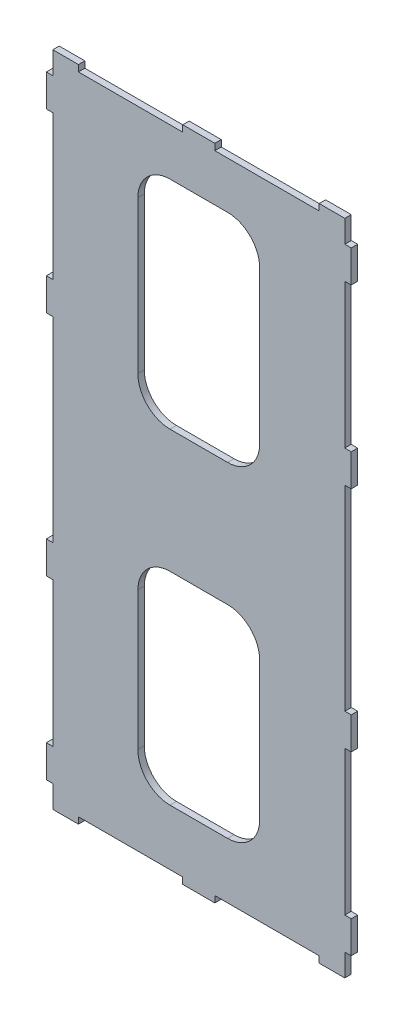
from build123d import *

# Parameters (mm, degrees)
BOSS_EXTRUDE2_DEPTH = 4


with BuildPart() as part:
    # Sketch1 → Boss-Extrude2 (new body)
    with BuildSketch(Plane.XY):
        Polygon((-75, -201), (-10, -201), (-10, -205), (10, -205), (10, -201), (75, -201), (75, -205), (91, -205), (91, -191), (95, -191), (95, -171), (91, -171), (91, -81), (95, -81), (95, -61), (91, -61), (91, 61), (95, 61), (95, 81), (91, 81), (91, 171), (95, 171), (95, 191), (91, 191), (91, 205), (75, 205), (75, 201), (10, 201), (10, 205), (-10, 205), (-10, 201), (-75, 201), (-75, 205), (-91, 205), (-91, 191), (-95, 191), (-95, 171), (-91, 171), (-91, 81), (-95, 81), (-95, 61), (-91, 61), (-91, -61), (-95, -61), (-95, -81), (-91, -81), (-91, -171), (-95, -171), (-95, -191), (-91, -191), (-91, -205), (-75, -205), align=None)
        with BuildLine():
            Line((-17.949055326, 171.697819396), (17.949055326, 171.697819396))
            ThreePointArc((17.949055326, 171.697819396), (32.09119095, 165.83995502), (37.949055326, 151.697819396))
            Line((37.949055326, 151.697819396), (37.949055326, 56.741742537))
            ThreePointArc((37.949055326, 56.741742537), (32.09119095, 42.599606914), (17.949055326, 36.741742537))
            Line((17.949055326, 36.741742537), (-17.949055326, 36.741742537))
            ThreePointArc((-17.949055326, 36.741742537), (-32.09119095, 42.599606914), (-37.949055326, 56.741742537))
            Line((-37.949055326, 56.741742537), (-37.949055326, 151.697819396))
            ThreePointArc((-37.949055326, 151.697819396), (-32.09119095, 165.83995502), (-17.949055326, 171.697819396))
        make_face(mode=Mode.SUBTRACT)
        with BuildLine():
            Line((-17.949055326, -166.180135652), (17.949055326, -166.180135652))
            ThreePointArc((17.949055326, -166.180135652), (32.09119095, -160.322271276), (37.949055326, -146.180135652))
            Line((37.949055326, -146.180135652), (37.949055326, -60))
            ThreePointArc((37.949055326, -60), (32.09119095, -45.857864376), (17.949055326, -40))
            Line((17.949055326, -40), (-17.949055326, -40))
            ThreePointArc((-17.949055326, -40), (-32.09119095, -45.857864376), (-37.949055326, -60))
            Line((-37.949055326, -60), (-37.949055326, -146.180135652))
            ThreePointArc((-37.949055326, -146.180135652), (-32.09119095, -160.322271276), (-17.949055326, -166.180135652))
        make_face(mode=Mode.SUBTRACT)
    extrude(amount=BOSS_EXTRUDE2_DEPTH)


solid = part.part
